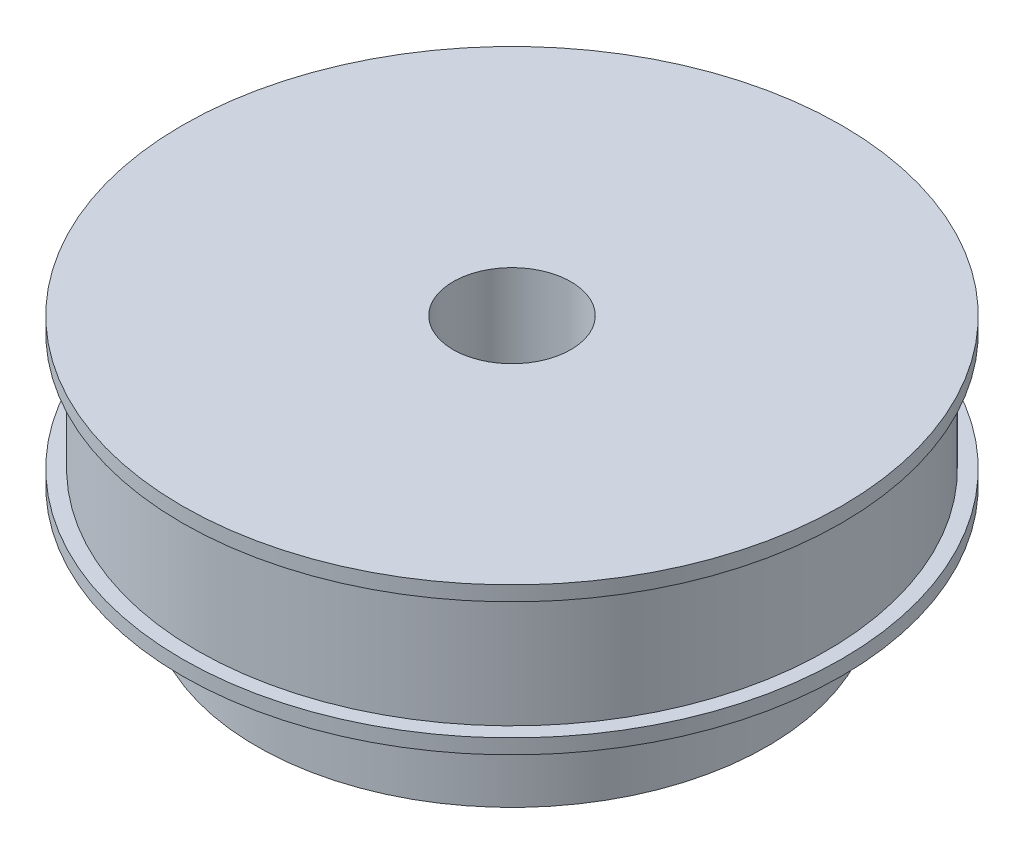
from build123d import *

# Parameters (mm, degrees)
SKETCH1_R           = 32.085
BOSS_EXTRUDE1_DEPTH = 12
SKETCH3_R           = 33.585
BOSS_EXTRUDE3_DEPTH = 1.5
SKETCH4_R           = 33.585
BOSS_EXTRUDE4_DEPTH = 1.5
SKETCH5_R           = 26
BOSS_EXTRUDE5_DEPTH = 10
SKETCH6_R           = 6
CUT_EXTRUDE1_DEPTH  = 25


with BuildPart() as part:
    # Sketch1 → Boss-Extrude1 (new body)
    with BuildSketch(Plane(origin=(0, 0, 0), x_dir=(1, 0, 0), z_dir=(0, 1, 0))):
        Circle(SKETCH1_R)
    extrude(amount=BOSS_EXTRUDE1_DEPTH)

    # Sketch3 → Boss-Extrude3 (add)
    with BuildSketch(Plane(origin=(0, 12, 0), x_dir=(1, 0, 0), z_dir=(0, 1, 0))):
        Circle(SKETCH3_R)
    extrude(amount=BOSS_EXTRUDE3_DEPTH)

    # Sketch4 → Boss-Extrude4 (add)
    with BuildSketch(Plane.XZ):
        Circle(SKETCH4_R)
    extrude(amount=BOSS_EXTRUDE4_DEPTH)

    # Sketch5 → Boss-Extrude5 (add)
    with BuildSketch(Plane.XZ.offset(1.5)):
        Circle(SKETCH5_R)
    extrude(amount=BOSS_EXTRUDE5_DEPTH)

    # Sketch6 → Cut-Extrude1 (cut)
    with BuildSketch(Plane(origin=(0, 13.5, 0), x_dir=(1, 0, 0), z_dir=(0, 1, 0))):
        Circle(SKETCH6_R)
    extrude(amount=-CUT_EXTRUDE1_DEPTH, mode=Mode.SUBTRACT)


solid = part.part
